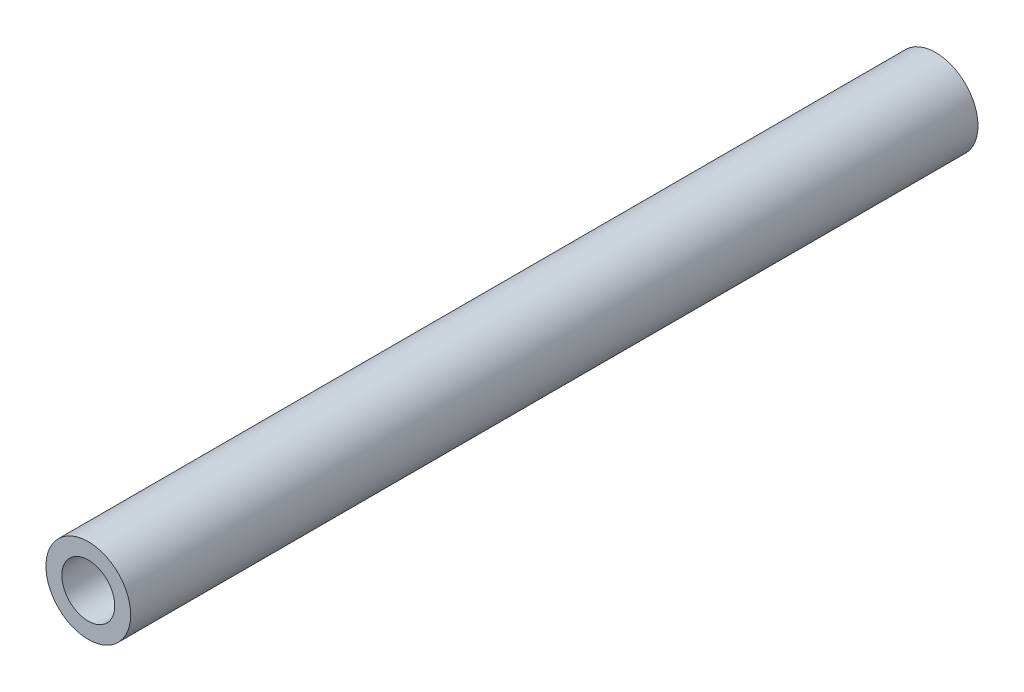
from build123d import *

# Parameters (mm, degrees)
SKETCH_1_R      = 1.6
SKETCH_1_R_2    = 1
EXTRUDE_1_DEPTH = 32


with BuildPart() as part:
    # 草图1 → 凸台-拉伸1 (new body)
    with BuildSketch(Plane.XY):
        Circle(SKETCH_1_R)
        Circle(SKETCH_1_R_2, mode=Mode.SUBTRACT)
    extrude(amount=EXTRUDE_1_DEPTH)


solid = part.part
